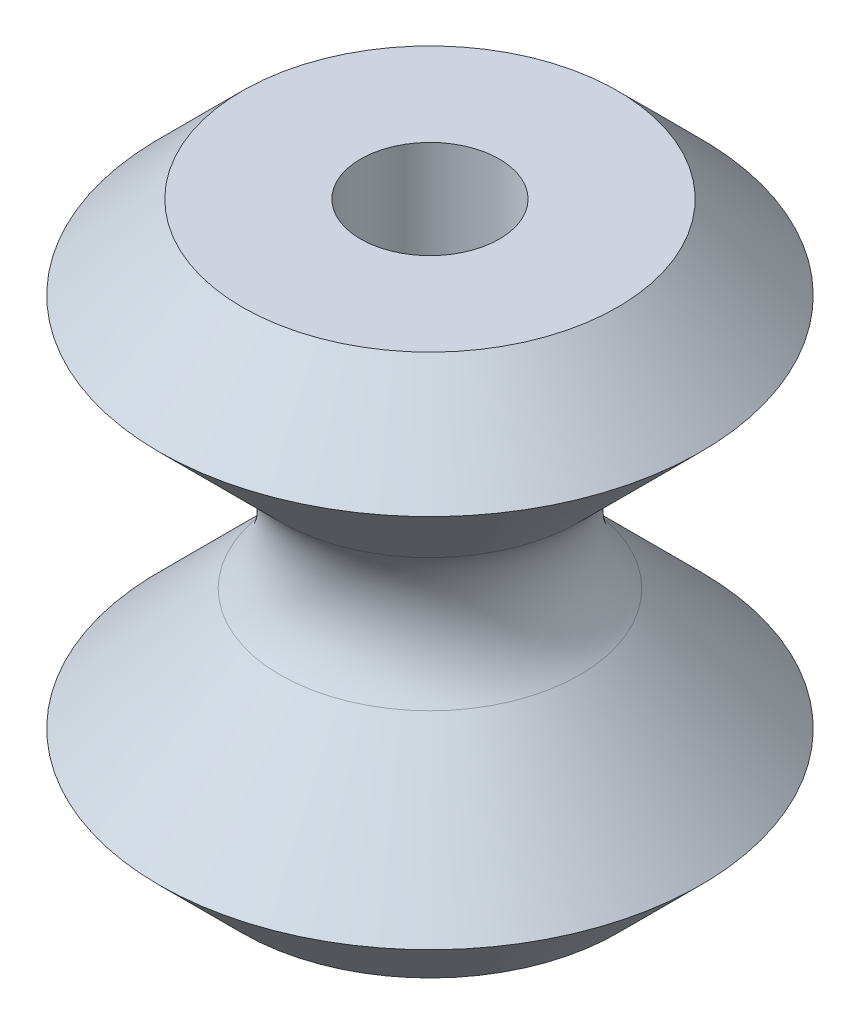
from build123d import *

# Parameters (mm, degrees)
SKETCH3_R          = 2.3495
CUT_EXTRUDE1_DEPTH = 19.3515
FILLET1_R          = 3.175


with BuildPart() as part:
    # Sketch2 → Revolve1 (revolve)
    with BuildSketch(Plane.XY):
        Polygon((9.17575, 2.82575), (6.35, 0), (0, 0), (0, 18.3515), (6.35, 18.3515), (9.17575, 15.52575), (2.82575, 9.17575), align=None)
    revolve(axis=Axis((0, 18.3515, 0), (0, -1, 0)))

    # Sketch3 → Cut-Extrude1 (cut, through all)
    with BuildSketch(Plane(origin=(0, 18.3515, 0), x_dir=(1, 0, 0), z_dir=(0, 1, 0))):
        Circle(SKETCH3_R)
    extrude(amount=-CUT_EXTRUDE1_DEPTH, mode=Mode.SUBTRACT)

    # Fillet1
    fillet1_edges = [part.edges().sort_by_distance(p)[0] for p in [
        (-2.82575, 9.17575, 0),
    ]]
    fillet(fillet1_edges, radius=FILLET1_R)


solid = part.part
